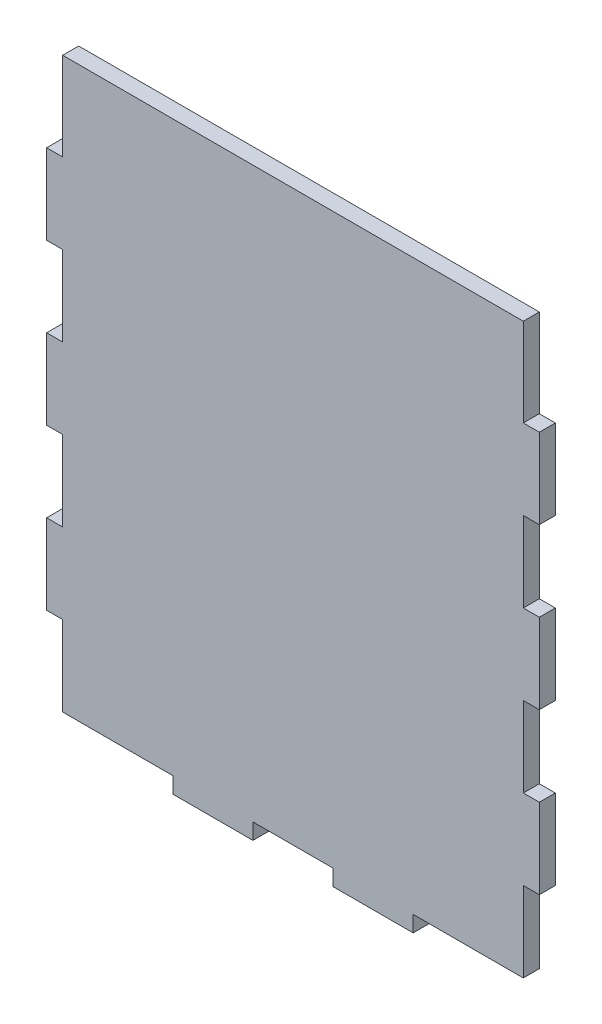
from build123d import *

# Parameters (mm, degrees)
EXTRUDE_1_DEPTH = 4


with BuildPart() as part:
    # Эскиз1 → Бобышка-Вытянуть1 (new body)
    with BuildSketch(Plane.XY):
        Polygon((27.5, 0), (27.5, -4), (47.5, -4), (47.5, 0), (67.5, 0), (67.5, -4), (87.5, -4), (87.5, 0), (115, 0), (115, 20), (119, 20), (119, 40), (115, 40), (115, 60), (119, 60), (119, 80), (115, 80), (115, 100), (119, 100), (119, 120), (115, 120), (115, 142), (0, 142), (0, 120), (-4, 120), (-4, 100), (0, 100), (0, 80), (-4, 80), (-4, 60), (0, 60), (0, 40), (-4, 40), (-4, 20), (0, 20), (0, 0), align=None)
    extrude(amount=EXTRUDE_1_DEPTH)


solid = part.part
